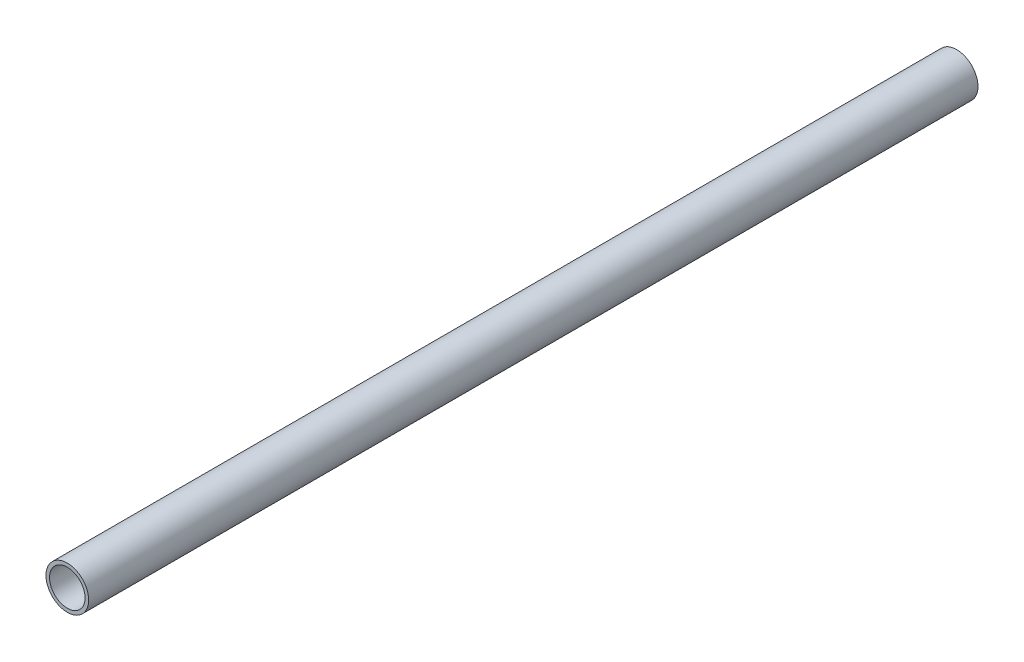
from build123d import *

# Parameters (mm, degrees)
ESQUISSE1_R        = 6
ESQUISSE1_R_2      = 5
BOSS_EXTRU_1_DEPTH = 250


with BuildPart() as part:
    # Esquisse1 → Boss.-Extru.1 (new body)
    with BuildSketch(Plane.XY):
        Circle(ESQUISSE1_R)
        Circle(ESQUISSE1_R_2, mode=Mode.SUBTRACT)
    extrude(amount=BOSS_EXTRU_1_DEPTH)


solid = part.part
